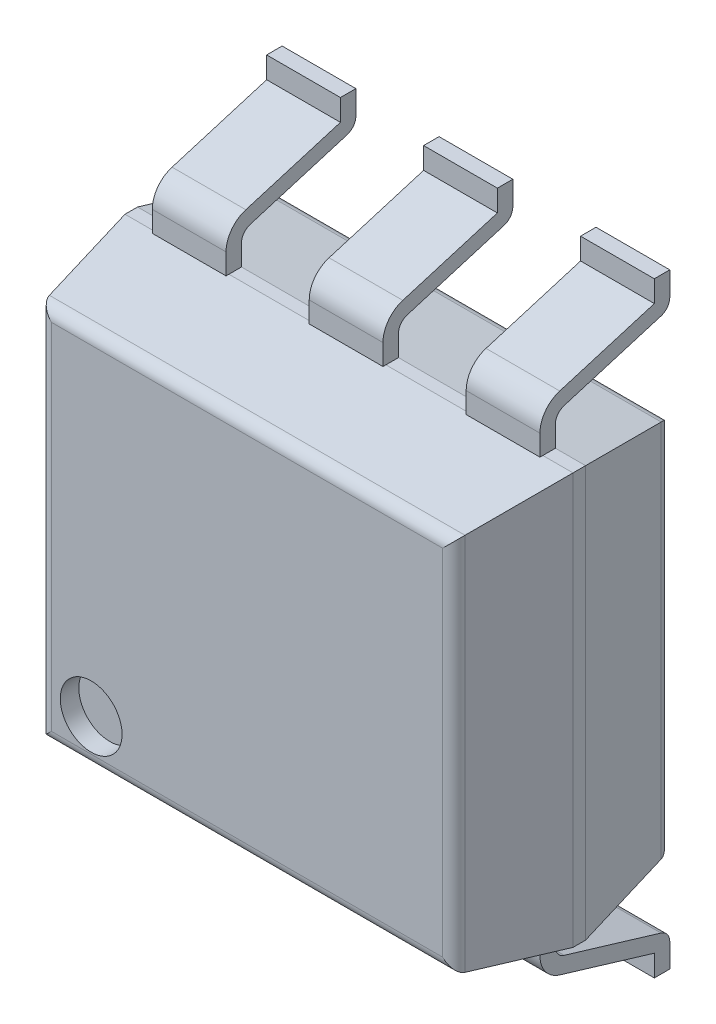
from build123d import *

# Parameters (mm, degrees)
SKETCH1_W                = 7.25
SKETCH1_H                = 6.65
BASE_EXTRUDE_DEPTH       = 3.5052
CHAMFER1_SIZE            = 1.651
CHAMFER1_SIZE2           = 0.291115845
CHAMFER1_PART_2_SIZE     = 1.651
CHAMFER1_PART_2_SIZE2    = 0.291115845
CHAMFER1_PART_3_SIZE     = 1.651
CHAMFER1_PART_3_SIZE2    = 0.291115845
CHAMFER1_PART_4_SIZE     = 1.651
CHAMFER1_PART_4_SIZE2    = 0.291115845
CHAMFER2_SIZE            = 1.651
CHAMFER2_SIZE2           = 0.291115845
CHAMFER2_PART_2_SIZE     = 1.651
CHAMFER2_PART_2_SIZE2    = 0.291115845
CHAMFER2_PART_3_SIZE     = 1.651
CHAMFER2_PART_3_SIZE2    = 0.291115845
CHAMFER2_PART_4_SIZE     = 1.651
CHAMFER2_PART_4_SIZE2    = 0.291115845
SKETCH3_R                = 0.5
CUT_EXTRUDE1_DEPTH       = 0.3
BOSS_EXTRUDE_THIN3_DEPTH = 0.5969
LPATTERN1_COUNT          = 3
LPATTERN1_PITCH          = 2.54
MIRROR1_COPY_1_DEPTH     = 0.5969
MIRROR1_COPY_2_DEPTH     = 0.5969
FILLET_1_R               = 0.2


with BuildPart() as part:
    # Sketch1 → Base-Extrude (new body)
    with BuildSketch(Plane.XY):
        with Locations((2.99, 4.214)):
            Rectangle(SKETCH1_W, SKETCH1_H)
    extrude(amount=BASE_EXTRUDE_DEPTH)

    # Chamfer1
    chamfer1_edges = [part.edges().sort_by_distance(p)[0] for p in [
        (6.615, 4.214, 3.5052),
    ]]
    chamfer1_side = [part.faces().sort_by_distance(p)[0] for p in [
        (6.615, 4.214, 1.7526),
    ]]
    chamfer(chamfer1_edges, length=CHAMFER1_SIZE, length2=CHAMFER1_SIZE2, reference=chamfer1_side[0])

    # Chamfer1 part 2
    chamfer1_part_2_edges = [part.edges().sort_by_distance(p)[0] for p in [
        (2.99, 7.539, 3.5052),
    ]]
    chamfer1_part_2_side = [part.faces().sort_by_distance(p)[0] for p in [
        (2.99, 7.539, 1.7526),
    ]]
    chamfer(chamfer1_part_2_edges, length=CHAMFER1_PART_2_SIZE, length2=CHAMFER1_PART_2_SIZE2, reference=chamfer1_part_2_side[0])

    # Chamfer1 part 3
    chamfer1_part_3_edges = [part.edges().sort_by_distance(p)[0] for p in [
        (-0.635, 4.214, 3.5052),
    ]]
    chamfer1_part_3_side = [part.faces().sort_by_distance(p)[0] for p in [
        (-0.635, 4.214, 1.7526),
    ]]
    chamfer(chamfer1_part_3_edges, length=CHAMFER1_PART_3_SIZE, length2=CHAMFER1_PART_3_SIZE2, reference=chamfer1_part_3_side[0])

    # Chamfer1 part 4
    chamfer1_part_4_edges = [part.edges().sort_by_distance(p)[0] for p in [
        (2.99, 0.889, 3.5052),
    ]]
    chamfer1_part_4_side = [part.faces().sort_by_distance(p)[0] for p in [
        (2.99, 0.889, 1.7526),
    ]]
    chamfer(chamfer1_part_4_edges, length=CHAMFER1_PART_4_SIZE, length2=CHAMFER1_PART_4_SIZE2, reference=chamfer1_part_4_side[0])

    # Chamfer2
    chamfer2_edges = [part.edges().sort_by_distance(p)[0] for p in [
        (2.99, 7.539, 0),
    ]]
    chamfer2_side = [part.faces().sort_by_distance(p)[0] for p in [
        (2.99, 7.539, 0.9271),
    ]]
    chamfer(chamfer2_edges, length=CHAMFER2_SIZE, length2=CHAMFER2_SIZE2, reference=chamfer2_side[0])

    # Chamfer2 part 2
    chamfer2_part_2_edges = [part.edges().sort_by_distance(p)[0] for p in [
        (6.615, 4.214, 0),
    ]]
    chamfer2_part_2_side = [part.faces().sort_by_distance(p)[0] for p in [
        (6.615, 4.214, 0.9271),
    ]]
    chamfer(chamfer2_part_2_edges, length=CHAMFER2_PART_2_SIZE, length2=CHAMFER2_PART_2_SIZE2, reference=chamfer2_part_2_side[0])

    # Chamfer2 part 3
    chamfer2_part_3_edges = [part.edges().sort_by_distance(p)[0] for p in [
        (2.99, 0.889, 0),
    ]]
    chamfer2_part_3_side = [part.faces().sort_by_distance(p)[0] for p in [
        (2.99, 0.889, 0.9271),
    ]]
    chamfer(chamfer2_part_3_edges, length=CHAMFER2_PART_3_SIZE, length2=CHAMFER2_PART_3_SIZE2, reference=chamfer2_part_3_side[0])

    # Chamfer2 part 4
    chamfer2_part_4_edges = [part.edges().sort_by_distance(p)[0] for p in [
        (-0.635, 4.214, 0),
    ]]
    chamfer2_part_4_side = [part.faces().sort_by_distance(p)[0] for p in [
        (-0.635, 4.214, 0.9271),
    ]]
    chamfer(chamfer2_part_4_edges, length=CHAMFER2_PART_4_SIZE, length2=CHAMFER2_PART_4_SIZE2, reference=chamfer2_part_4_side[0])

    # Sketch3 → Cut-Extrude1 (cut)
    with BuildSketch(Plane(origin=(0.118935742, 0.142956615, 3.5052), x_dir=(1, 0, 0), z_dir=(0, 0, 1))):
        with Locations((0.349775267, 1.734053999)):
            Circle(SKETCH3_R)
    extrude(amount=-CUT_EXTRUDE1_DEPTH, mode=Mode.SUBTRACT)

    # Sketch4 → Boss-Extrude-Thin3 (add, symmetric)
    with BuildSketch(Plane.ZY.offset(-0.45)):
        with BuildLine():
            Line((1.651, 0.889), (1.651, 0.552741678))
            ThreePointArc((1.651, 0.552741678), (1.61148335, 0.433388864), (1.508549057, 0.361200283))
            Line((1.508549057, 0.361200283), (-0.057549057, -0.109337536))
            ThreePointArc((-0.057549057, -0.109337536), (-0.16048335, -0.181526117), (-0.2, -0.300878931))
            Line((-0.2, -0.300878931), (-0.2, -0.686))
            Line((-0.2, -0.686), (0.05, -0.686))
            Line((0.05, -0.686), (0.05, -0.33806435))
            Line((0.05, -0.33806435), (1.580485379, 0.121773539))
            ThreePointArc((1.580485379, 0.121773539), (1.812087538, 0.284197846), (1.901, 0.552741678))
            Line((1.901, 0.552741678), (1.901, 0.889))
            Line((1.901, 0.889), (1.651, 0.889))
        make_face()
    boss_extrude_thin3 = extrude(amount=BOSS_EXTRUDE_THIN3_DEPTH, both=True)

    # LPattern1: Boss-Extrude-Thin3 ×3
    with Locations(*[(i * LPATTERN1_PITCH, 0, 0) for i in range(1, LPATTERN1_COUNT)]):
        add(boss_extrude_thin3)

    # Mirror1: Boss-Extrude-Thin3 across plane
    add(boss_extrude_thin3.mirror(Plane(origin=(0, 4.214, 0), x_dir=(0, 0, 1), z_dir=(0, -1, 0))))

    # Mirror1 copy 1 sketch → Mirror1 copy 1 (add, symmetric)
    with BuildSketch(Plane(origin=(2.99, 8.428, 0), x_dir=(0, 0, 1), z_dir=(-1, 0, 0))):
        with BuildLine():
            Line((1.651, -0.889), (1.651, -0.552741678))
            ThreePointArc((1.651, -0.552741678), (1.61148335, -0.433388864), (1.508549057, -0.361200283))
            Line((1.508549057, -0.361200283), (-0.057549057, 0.109337536))
            ThreePointArc((-0.057549057, 0.109337536), (-0.16048335, 0.181526117), (-0.2, 0.300878931))
            Line((-0.2, 0.300878931), (-0.2, 0.686))
            Line((-0.2, 0.686), (0.05, 0.686))
            Line((0.05, 0.686), (0.05, 0.33806435))
            Line((0.05, 0.33806435), (1.580485379, -0.121773539))
            ThreePointArc((1.580485379, -0.121773539), (1.812087538, -0.284197846), (1.901, -0.552741678))
            Line((1.901, -0.552741678), (1.901, -0.889))
            Line((1.901, -0.889), (1.651, -0.889))
        make_face()
    extrude(amount=MIRROR1_COPY_1_DEPTH, both=True)

    # Mirror1 copy 2 sketch → Mirror1 copy 2 (add, symmetric)
    with BuildSketch(Plane(origin=(5.53, 8.428, 0), x_dir=(0, 0, 1), z_dir=(-1, 0, 0))):
        with BuildLine():
            Line((1.651, -0.889), (1.651, -0.552741678))
            ThreePointArc((1.651, -0.552741678), (1.61148335, -0.433388864), (1.508549057, -0.361200283))
            Line((1.508549057, -0.361200283), (-0.057549057, 0.109337536))
            ThreePointArc((-0.057549057, 0.109337536), (-0.16048335, 0.181526117), (-0.2, 0.300878931))
            Line((-0.2, 0.300878931), (-0.2, 0.686))
            Line((-0.2, 0.686), (0.05, 0.686))
            Line((0.05, 0.686), (0.05, 0.33806435))
            Line((0.05, 0.33806435), (1.580485379, -0.121773539))
            ThreePointArc((1.580485379, -0.121773539), (1.812087538, -0.284197846), (1.901, -0.552741678))
            Line((1.901, -0.552741678), (1.901, -0.889))
            Line((1.901, -0.889), (1.651, -0.889))
        make_face()
    extrude(amount=MIRROR1_COPY_2_DEPTH, both=True)

    # Скругление1
    fillet_1_edges = [part.edges().sort_by_distance(p)[0] for p in [
        (-0.343884155, 4.214, 3.5052),
        (2.99, 7.247884155, 3.5052),
        (6.323884155, 4.214, 3.5052),
        (2.99, 1.180115845, 3.5052),
        (-0.343884155, 4.214, 0),
        (2.99, 7.247884155, 0),
        (6.323884155, 4.214, 0),
        (2.99, 1.180115845, 0),
    ]]
    fillet(fillet_1_edges, radius=FILLET_1_R)


solid = part.part
